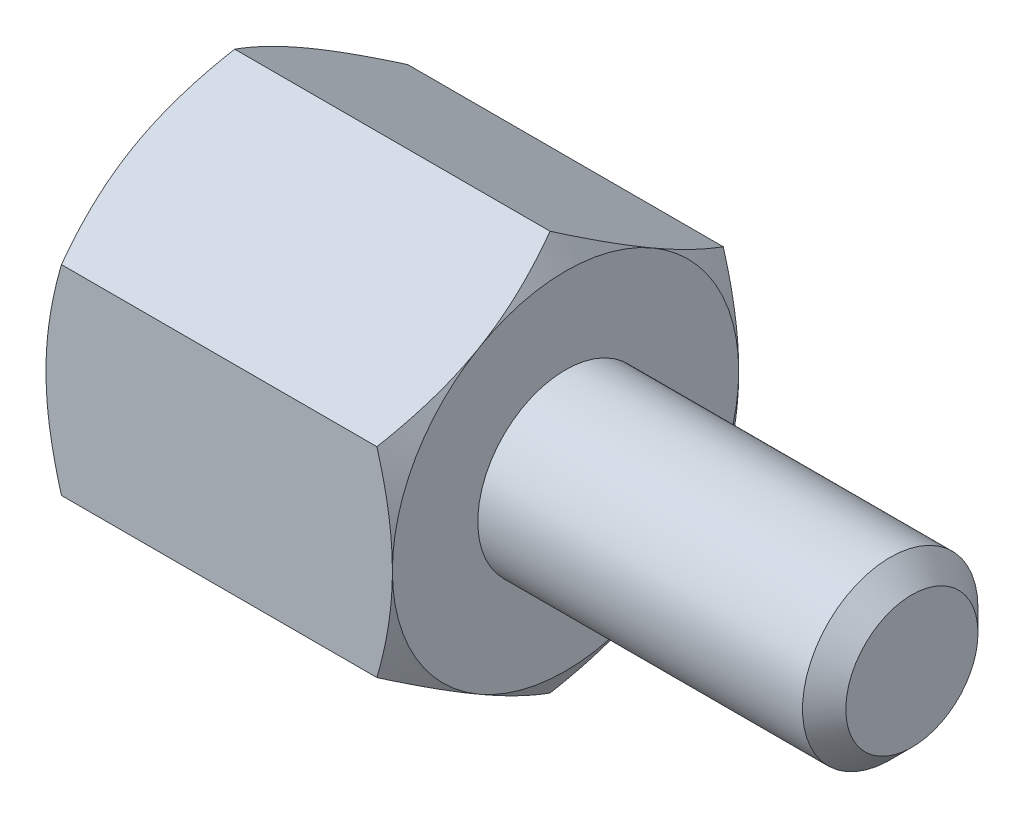
from build123d import *

# Parameters (mm, degrees)
SKETCH2_R         = 2.413
EXTRUDE1_DEPTH    = 9.525
CHAMFER1_SIZE     = 0.5953125
EXTRUDE4_DEPTH    = 9.525
SKETCH8_OUTSIDE_W = 85.776
SKETCH8_OUTSIDE_H = 87.248
SKETCH8_OUTSIDE_R = 4.7625
EXTRUDE5_DEPTH    = 20.05
EXTRUDE5_TAPER    = 60
SKETCH9_OUTSIDE_W = 52.78
SKETCH9_OUTSIDE_H = 54.252
SKETCH9_OUTSIDE_R = 4.7625
EXTRUDE6_DEPTH    = 10.525
EXTRUDE6_TAPER    = 60
SKETCH10_R        = 2.413
EXTRUDE7_DEPTH    = 4.7625


with BuildPart() as part:
    # Sketch2 → Extrude1 (new body)
    with BuildSketch(Plane(origin=(9.525, 0, 0), x_dir=(0, 0, -1), z_dir=(1, 0, 0))):
        Circle(SKETCH2_R)
    extrude(amount=-EXTRUDE1_DEPTH)

    # Chamfer1
    chamfer1_edges = [part.edges().sort_by_distance(p)[0] for p in [
        (9.525, 0, 2.413),
    ]]
    chamfer(chamfer1_edges, length=CHAMFER1_SIZE)

    # Sketch7 → Extrude4 (add)
    with BuildSketch(Plane(origin=(0, 0, 0), x_dir=(0, 0, -1), z_dir=(1, 0, 0))):
        Polygon((0, 5.499261314), (-4.7625, 2.749630657), (-4.7625, -2.749630657), (0, -5.499261314), (4.7625, -2.749630657), (4.7625, 2.749630657), align=None)
    extrude(amount=-EXTRUDE4_DEPTH)

    # Sketch8 outside → Extrude5 (cut, through all)
    with BuildSketch(Plane.ZY.offset(9.525)):
        Rectangle(SKETCH8_OUTSIDE_W, SKETCH8_OUTSIDE_H)
        Circle(SKETCH8_OUTSIDE_R, mode=Mode.SUBTRACT)
    extrude(amount=-EXTRUDE5_DEPTH, taper=EXTRUDE5_TAPER, mode=Mode.SUBTRACT)

    # Sketch9 outside → Extrude6 (cut, through all)
    with BuildSketch(Plane(origin=(0, 0, 0), x_dir=(0, 0, -1), z_dir=(1, 0, 0))):
        Rectangle(SKETCH9_OUTSIDE_W, SKETCH9_OUTSIDE_H)
        Circle(SKETCH9_OUTSIDE_R, mode=Mode.SUBTRACT)
    extrude(amount=-EXTRUDE6_DEPTH, taper=EXTRUDE6_TAPER, mode=Mode.SUBTRACT)

    # Sketch10 → Extrude7 (cut)
    with BuildSketch(Plane.ZY.offset(9.525)):
        Circle(SKETCH10_R)
    extrude(amount=-EXTRUDE7_DEPTH, mode=Mode.SUBTRACT)


solid = part.part
